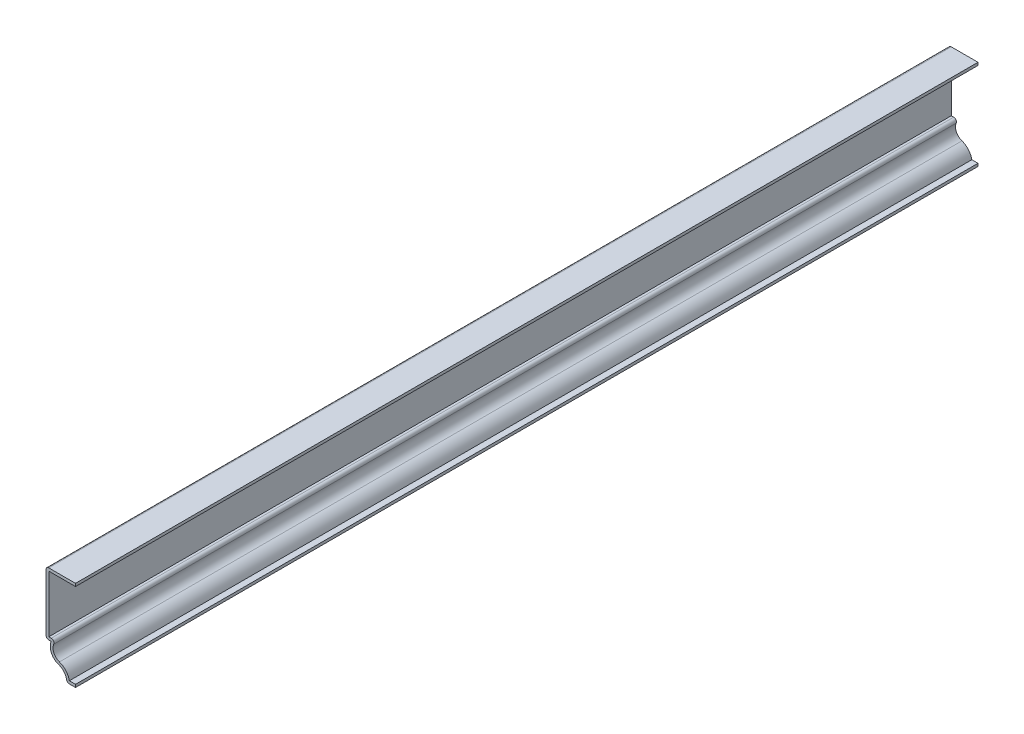
from build123d import *

# Parameters (mm, degrees)
EXTRUDE_THIN1_DEPTH = 412.75
FILLET1_R           = 1.27


with BuildPart() as part:
    # Sketch1 → Extrude-Thin1 (new body)
    with BuildSketch(Plane.XY):
        with BuildLine():
            Line((0, 0), (-3.96875, 0))
            ThreePointArc((-3.96875, 0), (-5.015027953, 3.245314499), (-7.759819948, 5.268401413))
            ThreePointArc((-7.759819948, 5.268401413), (-11.059343721, 8.251920066), (-11.1125, 12.7))
            Line((-11.1125, 12.7), (-13.49375, 12.7))
            Line((-13.49375, 12.7), (-13.49375, 41.275))
            Line((-13.49375, 41.275), (0, 41.275))
            Line((0, 41.275), (0, 40.005))
            Line((0, 40.005), (-12.22375, 40.005))
            Line((-12.22375, 40.005), (-12.22375, 13.97))
            Line((-12.22375, 13.97), (-8.560784129, 13.97))
            ThreePointArc((-8.560784129, 13.97), (-10.226629277, 9.856946266), (-7.356350222, 6.47260745))
            ThreePointArc((-7.356350222, 6.47260745), (-4.380937226, 4.48734969), (-2.81792992, 1.27))
            Line((-2.81792992, 1.27), (0, 1.27))
            Line((0, 1.27), (0, 0))
        make_face()
    extrude(amount=-EXTRUDE_THIN1_DEPTH)

    # Fillet1
    fillet1_edges = [part.edges().sort_by_distance(p)[0] for p in [
        (-8.560784129, 13.97, -206.375),
        (-3.96875, 0, -206.375),
        (-13.49375, 12.7, -206.375),
        (-13.49375, 41.275, -206.375),
    ]]
    fillet(fillet1_edges, radius=FILLET1_R)


solid = part.part
